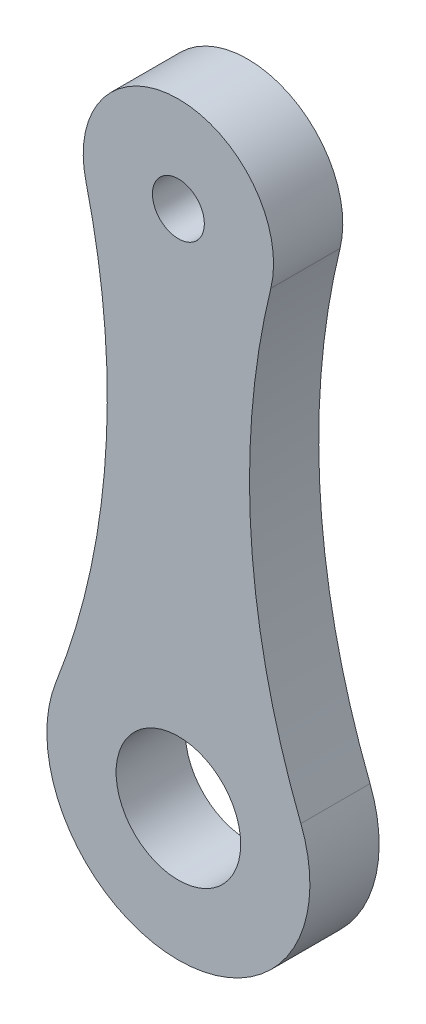
from build123d import *

# Parameters (mm, degrees)
SKETCH1_R           = 1.5
SKETCH1_R_2         = 3.6
BOSS_EXTRUDE1_DEPTH = 4


with BuildPart() as part:
    # Sketch1 → Boss-Extrude1 (new body)
    with BuildSketch(Plane.XY):
        with BuildLine():
            ThreePointArc((5.342400641, 13.692806292), (4.205730773, 0.599053953), (7.075936479, -12.22671261))
            ThreePointArc((7.075936479, -12.22671261), (0, -22.6), (-7.075936479, -12.22671261))
            ThreePointArc((-7.075936479, -12.22671261), (-4.205730773, 0.599053953), (-5.342400641, 13.692806292))
            ThreePointArc((-5.342400641, 13.692806292), (0, 20.5), (5.342400641, 13.692806292))
        make_face()
        with Locations((0, 15)):
            Circle(SKETCH1_R, mode=Mode.SUBTRACT)
        with Locations((0, -15)):
            Circle(SKETCH1_R_2, mode=Mode.SUBTRACT)
    extrude(amount=BOSS_EXTRUDE1_DEPTH)


solid = part.part
